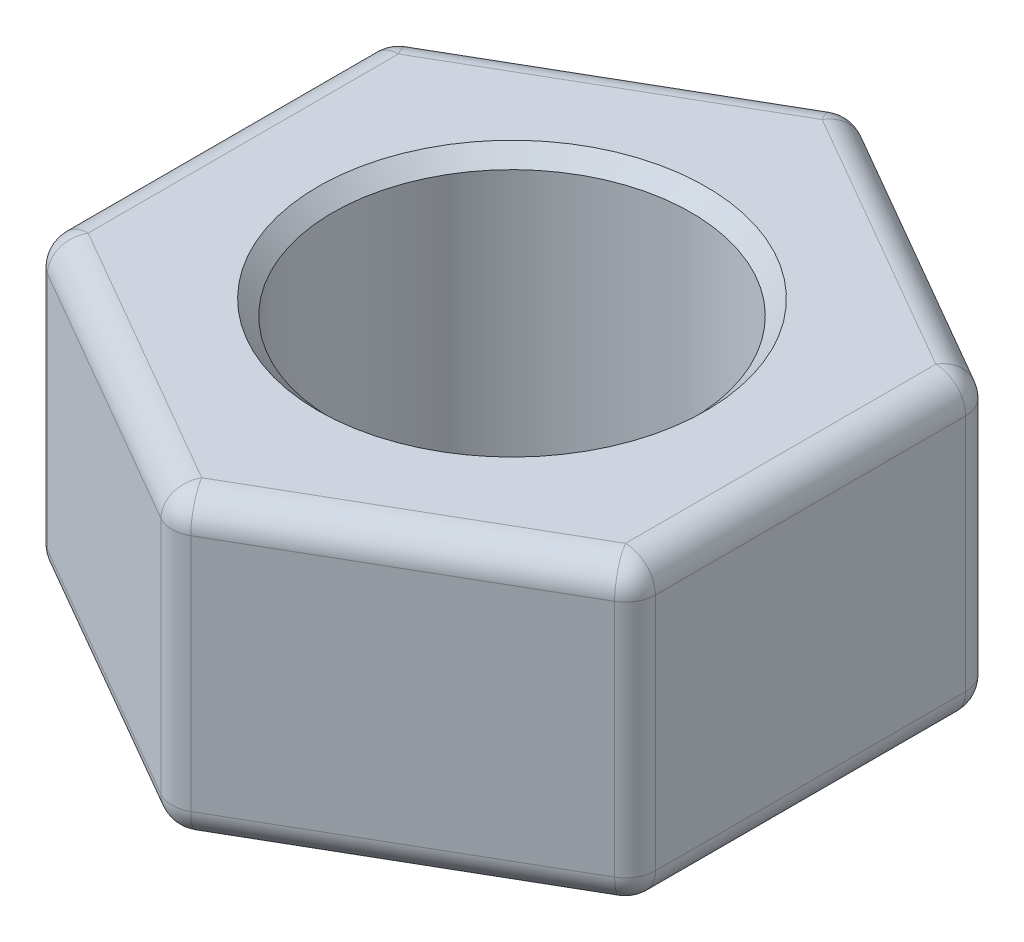
from build123d import *

# Parameters (mm, degrees)
ESQUISSE1_R        = 3
BOSS_EXTRU_1_DEPTH = 5
CONG_2_R           = 0.5
CHANFREIN1_SIZE    = 0.25


with BuildPart() as part:
    # Esquisse1 → Boss.-Extru.1 (new body)
    with BuildSketch(Plane(origin=(0, 0, 0), x_dir=(1, 0, 0), z_dir=(0, 1, 0))):
        Polygon((0, 5.773502692), (-5, 2.886751346), (-5, -2.886751346), (0, -5.773502692), (5, -2.886751346), (5, 2.886751346), align=None)
        Circle(ESQUISSE1_R, mode=Mode.SUBTRACT)
    extrude(amount=BOSS_EXTRU_1_DEPTH)

    # Congé2
    cong_2_edges = [part.edges().sort_by_distance(p)[0] for p in [
        (-5, 5, 0),
        (5, 2.5, -2.886751346),
        (5, 2.5, 2.886751346),
        (0, 2.5, 5.773502692),
        (-5, 2.5, 2.886751346),
        (-5, 2.5, -2.886751346),
        (0, 2.5, -5.773502692),
        (-2.5, 5, 4.330127019),
        (2.5, 5, 4.330127019),
        (5, 5, 0),
        (2.5, 5, -4.330127019),
        (5, 0, 0),
        (2.5, 0, 4.330127019),
        (-2.5, 0, 4.330127019),
        (-2.5, 5, -4.330127019),
        (-5, 0, 0),
        (-2.5, 0, -4.330127019),
        (2.5, 0, -4.330127019),
    ]]
    fillet(cong_2_edges, radius=CONG_2_R)

    # Chanfrein1
    chanfrein1_edges = [part.edges().sort_by_distance(p)[0] for p in [
        (-3, 0, 0),
        (-3, 5, 0),
    ]]
    chamfer(chanfrein1_edges, length=CHANFREIN1_SIZE)


solid = part.part
